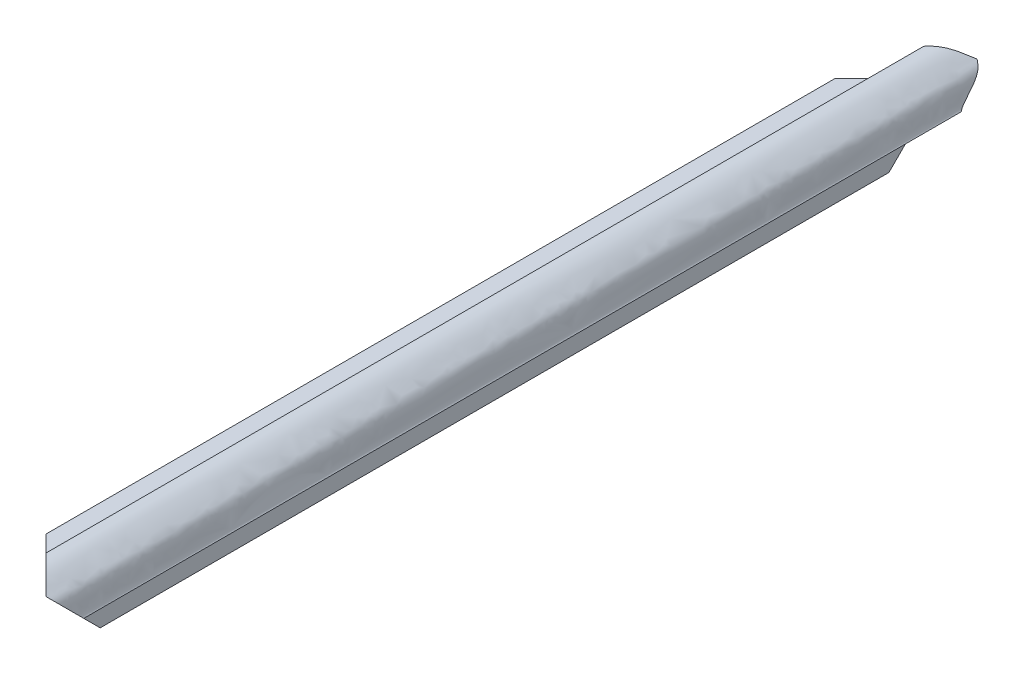
from build123d import *

# Parameters (mm, degrees)
SKETCH7_W               = 4.7625
SKETCH7_H               = 2.12122512
BOSS_EXTRUDE2_DEPTH     = 52.705
SKETCH8_W               = 2.12122512
SKETCH8_H               = 4.7625
BOSS_EXTRUDE3_DEPTH     = 52.705
BOSS_EXTRUDE4_DEPTH     = 52.705
CUT_EXTRUDE4_DEPTH      = 54.707262553
CUT_EXTRUDE4_DEPTH_BACK = 54.707262553
CUT_EXTRUDE5_DEPTH      = 53.064517001
CUT_EXTRUDE5_DEPTH_BACK = 53.064517001


with BuildPart() as part:
    # Sketch7 → Boss-Extrude2 (new, symmetric)
    with BuildSketch(Plane.XY):
        with Locations((-4.92125, -2.560612608)):
            Rectangle(SKETCH7_W, SKETCH7_H)
    extrude(amount=BOSS_EXTRUDE2_DEPTH, both=True)

    # Sketch8 → Boss-Extrude3 (add, symmetric)
    with BuildSketch(Plane.XY):
        with Locations((-2.560612608, -4.92125)):
            Rectangle(SKETCH8_W, SKETCH8_H)
    extrude(amount=BOSS_EXTRUDE3_DEPTH, both=True)

    # Sketch11 → Boss-Extrude4 (add, symmetric)
    with BuildSketch(Plane.XY):
        with BuildLine():
            Line((-2.54, 1.500000048), (-2.54, -1.500000048))
            Line((-2.54, -1.500000048), (-7.3025, -1.500000048))
            Line((-7.3025, -1.500000048), (-7.3025, -3.621225168))
            Line((-7.3025, -3.621225168), (-5.866289198, -3.621225168))
            Line((-5.866289198, -3.621225168), (-3.621225168, -5.866289198))
            Line((-3.621225168, -5.866289198), (-3.621225168, -7.3025))
            Line((-3.621225168, -7.3025), (-1.500000048, -7.3025))
            Line((-1.500000048, -7.3025), (-1.500000048, -2.54))
            Line((-1.500000048, -2.54), (1.500000048, -2.54))
            add(Edge.make_bspline(
                [(-2.54, 1.500000048), (-1.295649087, 1.635512934), (-0.042467258, 0.473225958), (1.297713539, -0.292226779), (1.263724591, -2.340394541), (1.500000048, -2.54)],
                knots=[0, 0, 0, 0, 0.496686972, 0.741346965, 0.899739924, 0.899739924, 0.899739924, 0.899739924], degree=3))
        make_face()
    extrude(amount=BOSS_EXTRUDE4_DEPTH, both=True)

    # Sketch14 → Cut-Extrude4 (cut, two sides: drawn at the far end of the back side and taken through both)
    with BuildSketch(Plane(origin=(0, 0, 0), x_dir=(1, 0, 0), z_dir=(0, 1, 0)).offset(-CUT_EXTRUDE4_DEPTH_BACK)):
        Polygon((-7.3025, -42.2275), (-7.3025, -56.8325), (7.3025, -56.8325), align=None)
        Polygon((-7.3025, 42.2275), (7.3025, 56.8325), (-7.3025, 56.8325), align=None)
    extrude(amount=CUT_EXTRUDE4_DEPTH + CUT_EXTRUDE4_DEPTH_BACK, mode=Mode.SUBTRACT)

    # Sketch17 → Cut-Extrude5 (cut, two sides: drawn at the far end of the back side and taken through both)
    with BuildSketch(Plane(origin=(0, 0, 0), x_dir=(0, -1, 0), z_dir=(-1, 0, 0)).offset(-CUT_EXTRUDE5_DEPTH_BACK)):
        Polygon((7.3025, 56.8325), (7.3025, 42.2275), (-7.3025, 56.8325), align=None)
        Polygon((7.3025, -42.2275), (-7.3025, -56.8325), (7.3025, -56.8325), align=None)
    extrude(amount=CUT_EXTRUDE5_DEPTH + CUT_EXTRUDE5_DEPTH_BACK, mode=Mode.SUBTRACT)


solid = part.part
